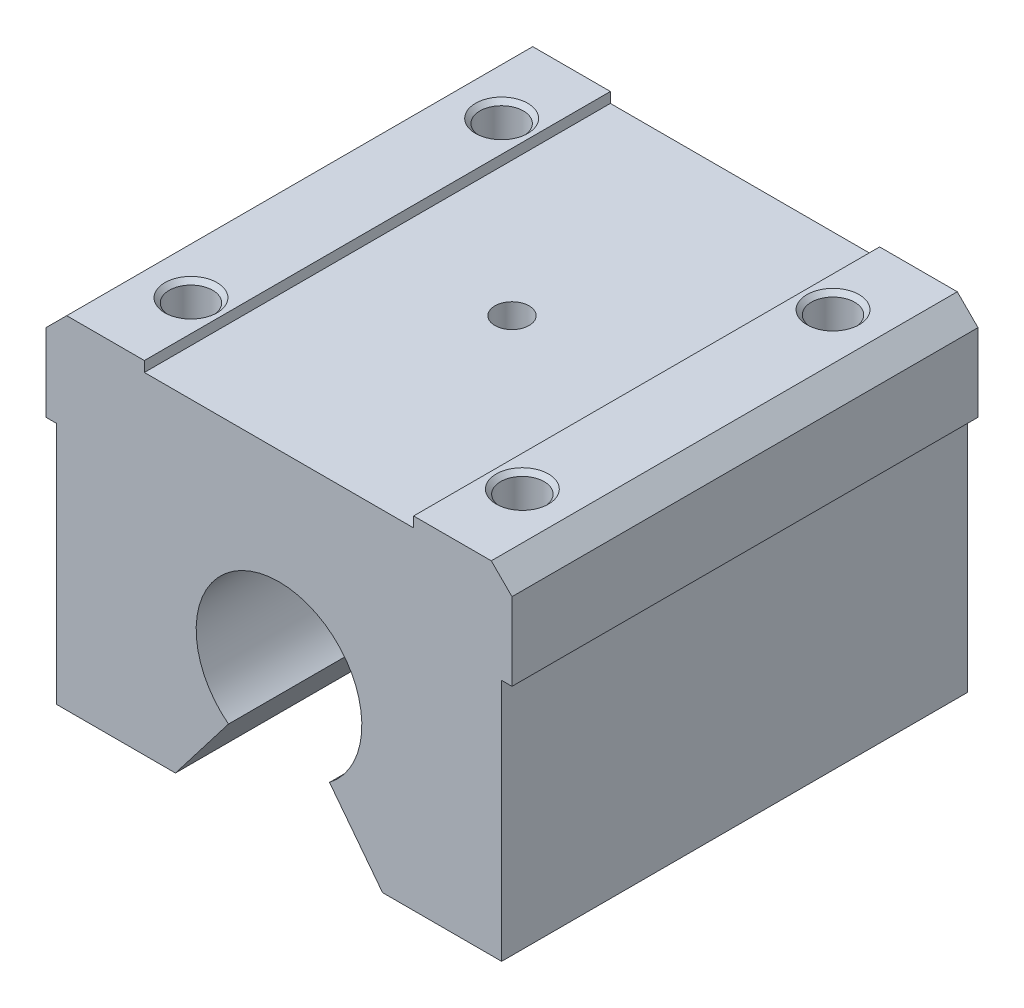
from build123d import *

# Parameters (mm, degrees)
BOSS_EXTRUDE1_DEPTH         = 22.5
M5_TAPPED_HOLE1_D           = 4.2
M5_TAPPED_HOLE1_DEPTH       = 12.4
M5_TAPPED_HOLE1_CSINK_D     = 5.05
M5_TAPPED_HOLE1_CSINK_ANGLE = 90
M5_TAPPED_HOLE1_TIP         = 1.2618073
M4X0_7_TAPPED_HOLE1_D       = 3.3
M4X0_7_TAPPED_HOLE1_DEPTH   = 10.1
M4X0_7_TAPPED_HOLE1_TIP     = 0.991420021
M6X1_0_TAPPED_HOLE1_D       = 5
M6X1_0_TAPPED_HOLE1_DEPTH   = 15
M6X1_0_TAPPED_HOLE1_TIP     = 1.502151548


with BuildPart() as part:
    # Sketch2 → Boss-Extrude1 (new body, symmetric)
    with BuildSketch(Plane.XY):
        with BuildLine():
            Line((13, 19), (-13, 19))
            Line((-13, 19), (-13, 20))
            Line((-13, 20), (-20.5, 20))
            Line((-20.5, 20), (-22.5, 18))
            Line((-22.5, 18), (-22.5, 10.5))
            Line((-22.5, 10.5), (-21.5, 10.5))
            Line((-21.5, 10.5), (-21.5, -13))
            Line((-21.5, -13), (-10, -13))
            Line((-10, -13), (-4.877686087, -6.340991913))
            ThreePointArc((-4.877686087, -6.340991913), (0, 8), (4.877686087, -6.340991913))
            Line((4.877686087, -6.340991913), (10, -13))
            Line((10, -13), (21.5, -13))
            Line((21.5, -13), (21.5, 10.5))
            Line((21.5, 10.5), (22.5, 10.5))
            Line((22.5, 10.5), (22.5, 18))
            Line((22.5, 18), (20.5, 20))
            Line((20.5, 20), (13, 20))
            Line((13, 20), (13, 19))
        make_face()
    extrude(amount=BOSS_EXTRUDE1_DEPTH, both=True)

    # M5 Tapped Hole1
    with Locations(Plane(origin=(0, 20, 0), x_dir=(1, 0, 0), z_dir=(0, 1, 0))):
        with Locations((-16, 15), (16, 15), (-16, -15), (16, -15)):
            CounterSinkHole(M5_TAPPED_HOLE1_D / 2, M5_TAPPED_HOLE1_CSINK_D / 2, depth=M5_TAPPED_HOLE1_DEPTH, counter_sink_angle=M5_TAPPED_HOLE1_CSINK_ANGLE)
            with Locations((0, 0, -(M5_TAPPED_HOLE1_DEPTH + M5_TAPPED_HOLE1_TIP / 2))):  # 118° drill point
                Cone(0, M5_TAPPED_HOLE1_D / 2, M5_TAPPED_HOLE1_TIP, mode=Mode.SUBTRACT)

    # M4x0.7 Tapped Hole1
    with Locations(Plane(origin=(0, 19, 0), x_dir=(1, 0, 0), z_dir=(0, 1, 0))):
        with Locations((0, 0)):
            Hole(M4X0_7_TAPPED_HOLE1_D / 2, depth=M4X0_7_TAPPED_HOLE1_DEPTH)
            with Locations((0, 0, -(M4X0_7_TAPPED_HOLE1_DEPTH + M4X0_7_TAPPED_HOLE1_TIP / 2))):  # 118° drill point
                Cone(0, M4X0_7_TAPPED_HOLE1_D / 2, M4X0_7_TAPPED_HOLE1_TIP, mode=Mode.SUBTRACT)

    # M6x1.0 Tapped Hole1
    with Locations(Plane.ZY.offset(21.5)):
        with Locations((0, 0)):
            Hole(M6X1_0_TAPPED_HOLE1_D / 2, depth=M6X1_0_TAPPED_HOLE1_DEPTH)
            with Locations((0, 0, -(M6X1_0_TAPPED_HOLE1_DEPTH + M6X1_0_TAPPED_HOLE1_TIP / 2))):  # 118° drill point
                Cone(0, M6X1_0_TAPPED_HOLE1_D / 2, M6X1_0_TAPPED_HOLE1_TIP, mode=Mode.SUBTRACT)


solid = part.part
